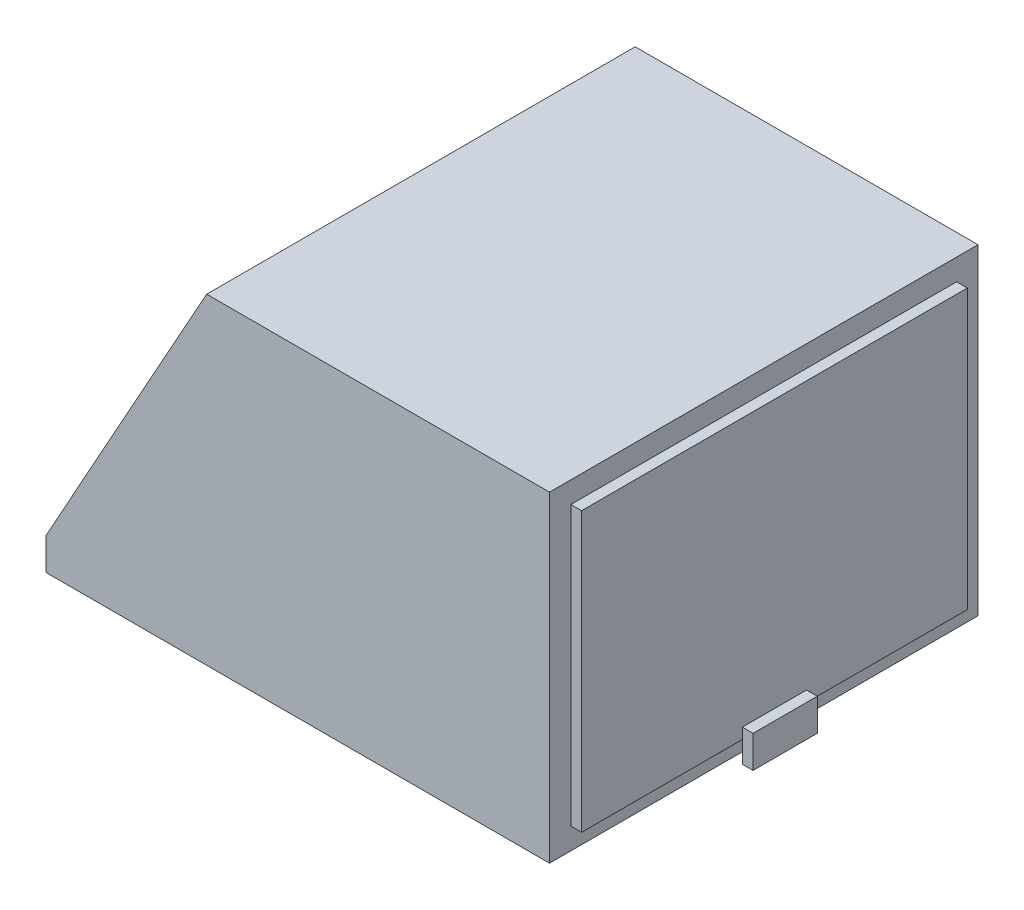
from build123d import *

# Parameters (mm, degrees)
SKETCH1_W           = 50
SKETCH1_H           = 30
BOSS_EXTRUDE1_DEPTH = 40
CUT_EXTRUDE15_DEPTH = 40
SKETCH33_W          = 38
SKETCH33_H          = 27.886890423
CUT_EXTRUDE16_DEPTH = 1
SKETCH36_W          = 3
SKETCH36_H          = 30
CUT_EXTRUDE17_DEPTH = 40
SKETCH37_W          = 36
SKETCH37_H          = 26
BOSS_EXTRUDE5_DEPTH = 1
SKETCH38_W          = 6
SKETCH38_H          = 3
BOSS_EXTRUDE6_DEPTH = 1


with BuildPart() as part:
    # Sketch1 → Boss-Extrude1 (new body)
    with BuildSketch(Plane.XY):
        with Locations((-9.745762712, 0.593220339)):
            Rectangle(SKETCH1_W, SKETCH1_H)
    extrude(amount=BOSS_EXTRUDE1_DEPTH)

    # Sketch29 → Cut-Extrude15 (cut)
    with BuildSketch(Plane.XY.offset(40)):
        Polygon((-34.745762712, -11.406779661), (-19.745762712, 15.593220339), (-34.745762712, 15.593220339), align=None)
    extrude(amount=-CUT_EXTRUDE15_DEPTH, mode=Mode.SUBTRACT)

    # Sketch33 → Cut-Extrude16 (cut)
    with BuildSketch(Plane(origin=(-21.708506556, 12.06028142, 0), x_dir=(0, 0, 1), z_dir=(-0.874157276, 0.485642931, 0))):
        with Locations((20, -11.401908276)):
            Rectangle(SKETCH33_W, SKETCH33_H)
    extrude(amount=-CUT_EXTRUDE16_DEPTH, mode=Mode.SUBTRACT)

    # Sketch36 → Cut-Extrude17 (cut)
    with BuildSketch(Plane.XY.offset(40)):
        with Locations((13.754237288, 0.593220339)):
            Rectangle(SKETCH36_W, SKETCH36_H)
    extrude(amount=-CUT_EXTRUDE17_DEPTH, mode=Mode.SUBTRACT)

    # Sketch37 → Boss-Extrude5 (add)
    with BuildSketch(Plane(origin=(12.254237288, 0, 0), x_dir=(0, 0, -1), z_dir=(1, 0, 0))):
        with Locations((-20, 0.593220339)):
            Rectangle(SKETCH37_W, SKETCH37_H)
    extrude(amount=BOSS_EXTRUDE5_DEPTH)

    # Sketch38 → Boss-Extrude6 (add)
    with BuildSketch(Plane(origin=(13.254237288, 0, 0), x_dir=(0, 0, -1), z_dir=(1, 0, 0))):
        with Locations((-20, -12.906779661)):
            Rectangle(SKETCH38_W, SKETCH38_H)
    extrude(amount=BOSS_EXTRUDE6_DEPTH)


solid = part.part
